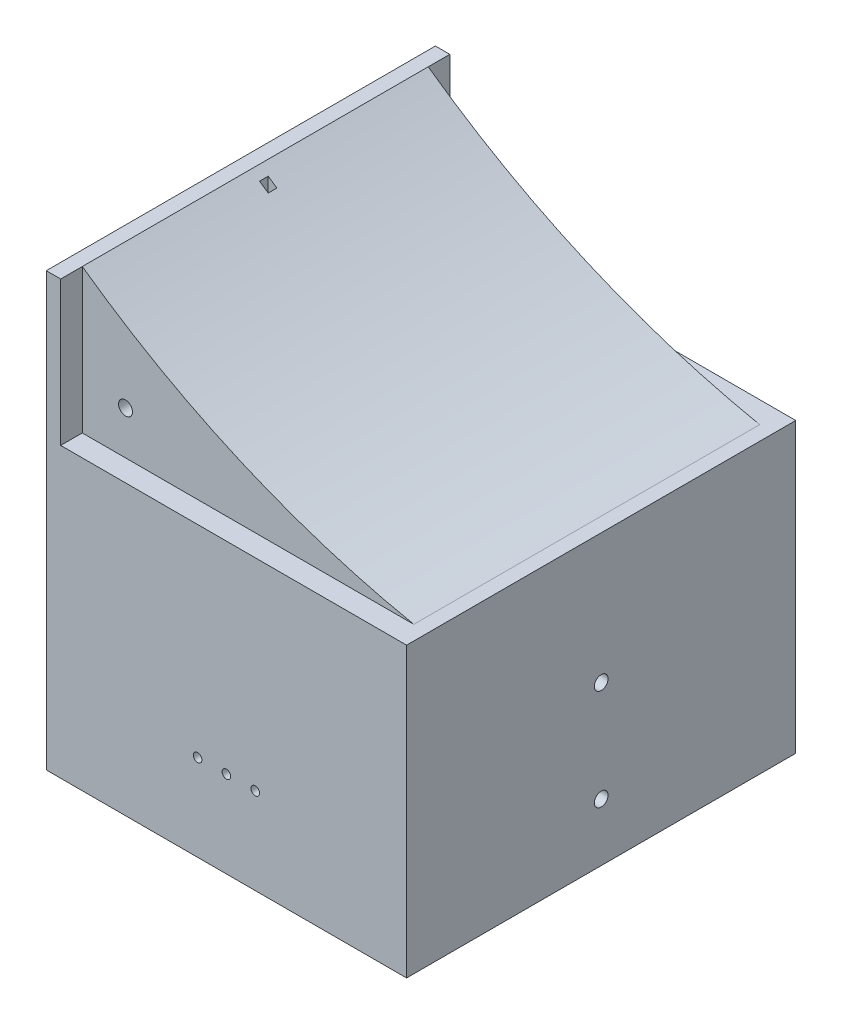
from build123d import *

# Parameters (mm, degrees)
BOSS_EXTRUDE2_DEPTH       = 60
SKETCH4_W                 = 120
SKETCH4_H                 = 100
BOSS_EXTRUDE3_DEPTH       = 7.5
SKETCH5_W                 = 135
SKETCH5_H                 = 150
BOSS_EXTRUDE4_DEPTH       = 5
SKETCH6_W                 = 112.3
SKETCH6_H                 = 75
CUT_EXTRUDE2_DEPTH        = 75
F_10_CLEARANCE_HOLE1_D    = 4.7752
F_2_CLEARANCE_HOLE1_D     = 2.032
F_2_CLEARANCE_HOLE1_DEPTH = 6.35
F_2_CLEARANCE_HOLE1_TIP   = 0.610474389
SKETCH17_W                = 3
SKETCH17_H                = 3
CUT_EXTRUDE4_DEPTH        = 76
SKETCH18_R                = 2.5
CUT_EXTRUDE5_DEPTH        = 27
SKETCH19_R                = 1.5
CUT_EXTRUDE6_DEPTH        = 4


with BuildPart() as part:
    # Sketch3 → Boss-Extrude2 (new body, symmetric)
    with BuildSketch(Plane.XY):
        with BuildLine():
            Line((0, 0), (120, 0))
            Line((120, 0), (120, 100))
            Line((120, 100), (115, 100))
            ThreePointArc((115, 100), (54.85834395, 118.924191085), (0, 150))
            Line((0, 150), (0, 0))
        make_face()
    extrude(amount=BOSS_EXTRUDE2_DEPTH, both=True)

    # Sketch4 → Boss-Extrude3 (add)
    with BuildSketch(Plane.XY.offset(60)):
        with Locations((60, 50)):
            Rectangle(SKETCH4_W, SKETCH4_H)
    boss_extrude3 = extrude(amount=BOSS_EXTRUDE3_DEPTH)

    # Mirror1: Boss-Extrude3 across plane
    add(boss_extrude3.mirror(Plane.XY))

    # Sketch5 → Boss-Extrude4 (add)
    with BuildSketch(Plane.ZY):
        with Locations((0, 75)):
            Rectangle(SKETCH5_W, SKETCH5_H)
    extrude(amount=BOSS_EXTRUDE4_DEPTH)

    # Sketch6 → Cut-Extrude2 (cut)
    with BuildSketch(Plane.XZ):
        with Locations((51.15, 0)):
            Rectangle(SKETCH6_W, SKETCH6_H)
    extrude(amount=-CUT_EXTRUDE2_DEPTH, mode=Mode.SUBTRACT)

    # #10 Clearance Hole1 (through all)
    with Locations(Plane.ZY.offset(-107.3)):
        with Locations((0, 55), (0, 20)):
            Hole(F_10_CLEARANCE_HOLE1_D / 2)

    # #2 Clearance Hole1
    with Locations(Plane(origin=(0, 75, 0), x_dir=(-1, 0, 0), z_dir=(0, -1, 0))):
        with Locations((-20, 18.5), (-72, -14.25), (-72, 13.75), (-21.143, -29.5)):
            Hole(F_2_CLEARANCE_HOLE1_D / 2, depth=F_2_CLEARANCE_HOLE1_DEPTH)
            with Locations((0, 0, -(F_2_CLEARANCE_HOLE1_DEPTH + F_2_CLEARANCE_HOLE1_TIP / 2))):  # 118° drill point
                Cone(0, F_2_CLEARANCE_HOLE1_D / 2, F_2_CLEARANCE_HOLE1_TIP, mode=Mode.SUBTRACT)

    # Sketch15 → #10 Clearance Hole2 (revolve, cut)
    with BuildSketch(Plane(origin=(15, 115, 60), x_dir=(0, -1, 0), z_dir=(1, 0, 0))):
        Polygon((0, 0), (0, 26.849876674), (2.413, 25.4), (2.413, 0), align=None)
    f_10_clearance_hole2 = revolve(axis=Axis((15, 115, 66.35), (0, 0, -1)), mode=Mode.SUBTRACT)

    # Mirror2: #10 Clearance Hole2 across plane
    add(f_10_clearance_hole2.mirror(Plane.XY), mode=Mode.SUBTRACT)

    # Sketch17 → Cut-Extrude4 (cut, through all)
    with BuildSketch(Plane.XZ.offset(-75)):
        with Locations((4.5, 0)):
            Rectangle(SKETCH17_W, SKETCH17_H)
    extrude(amount=-CUT_EXTRUDE4_DEPTH, mode=Mode.SUBTRACT)

    # Sketch18 → Cut-Extrude5 (cut)
    with BuildSketch(Plane(origin=(0, 0, 37.5), x_dir=(-1, 0, 0), z_dir=(0, 0, -1))):
        with Locations((-67.5, 30)):
            Circle(SKETCH18_R)
        with Locations((-57.5, 30)):
            Circle(SKETCH18_R)
        with Locations((-47.5, 30)):
            Circle(SKETCH18_R)
    extrude(amount=-CUT_EXTRUDE5_DEPTH, mode=Mode.SUBTRACT)

    # Sketch19 → Cut-Extrude6 (cut, through all)
    with BuildSketch(Plane(origin=(0, 0, 64.5), x_dir=(-1, 0, 0), z_dir=(0, 0, -1))):
        with Locations((-67.5, 30)):
            Circle(SKETCH19_R)
        with Locations((-57.5, 30)):
            Circle(SKETCH19_R)
        with Locations((-47.5, 30)):
            Circle(SKETCH19_R)
    extrude(amount=-CUT_EXTRUDE6_DEPTH, mode=Mode.SUBTRACT)


solid = part.part
